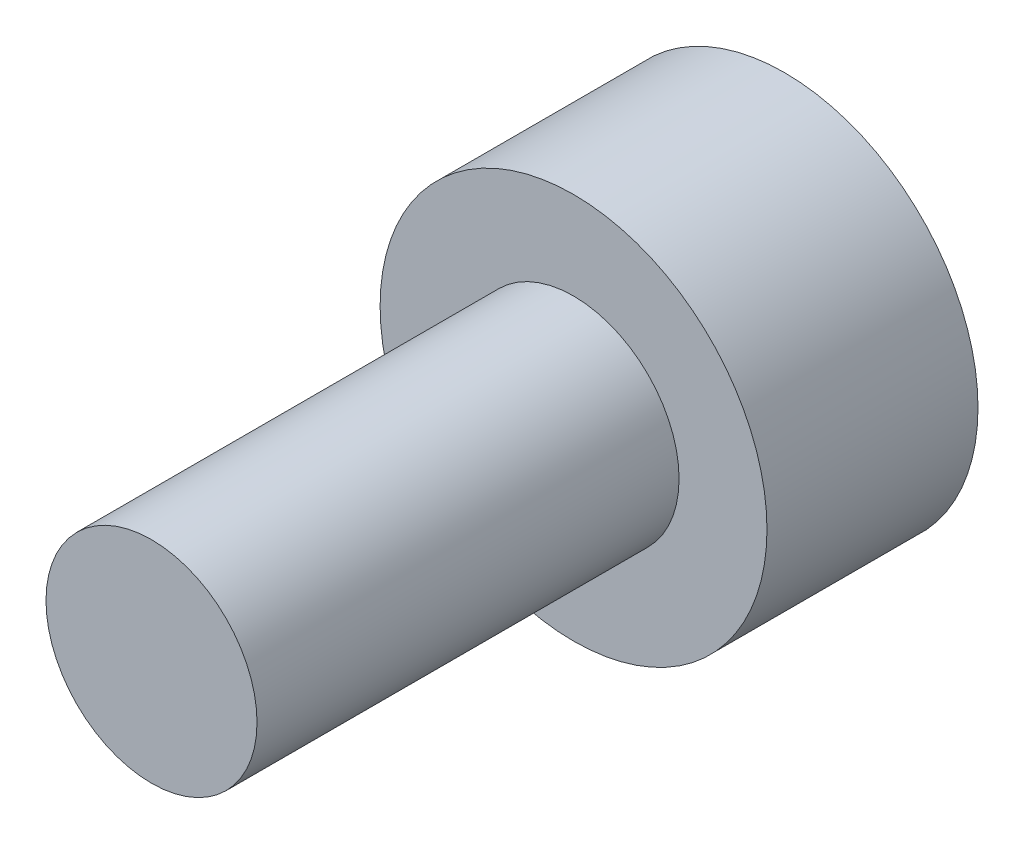
from build123d import *

# Parameters (mm, degrees)
CORTE_EXTRUS_O1_DEPTH = 1.5


with BuildPart() as part:
    # Esboço1 → Revolução1 (revolve)
    with BuildSketch(Plane(origin=(0, 0, 0), x_dir=(1, 0, 0), z_dir=(0, 1, 0))):
        Polygon((0, 0), (2.75, 0), (2.75, -3), (1.5, -3), (1.5, -9), (0, -9), (0, -3), align=None)
    revolve(axis=Axis((0, 0, 3), (0, 0, -1)))

    # Esboço2 → Corte-extrusão1 (cut)
    with BuildSketch(Plane(origin=(0, 0, 0), x_dir=(-1, 0, 0), z_dir=(0, 0, -1))):
        Polygon((1.732050808, 0), (0.866025404, 1.5), (-0.866025404, 1.5), (-1.732050808, 0), (-0.866025404, -1.5), (0.866025404, -1.5), align=None)
    extrude(amount=-CORTE_EXTRUS_O1_DEPTH, mode=Mode.SUBTRACT)


solid = part.part
